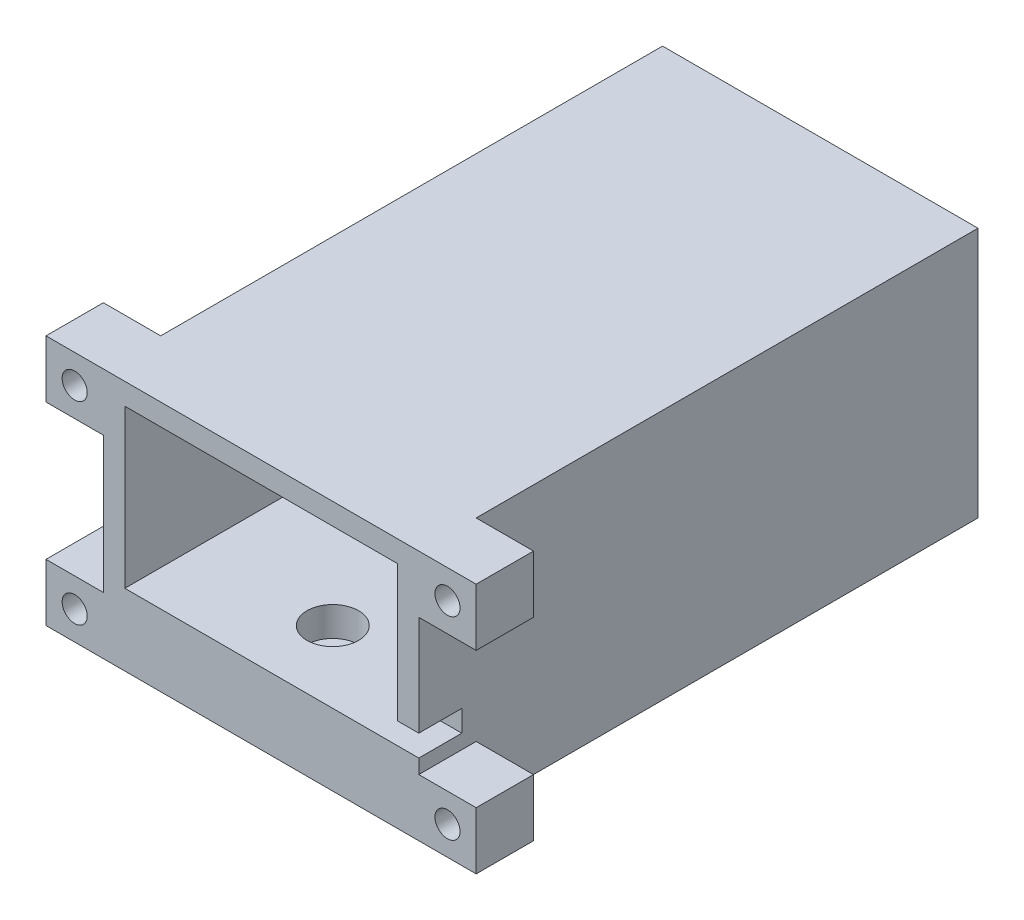
from build123d import *

# Parameters (mm, degrees)
SKETCH_1_W                 = 44
SKETCH_1_H                 = 78
EXTRUDE_1_DEPTH            = 35
SHELL_1_T                  = -3
SHELL_1_THICKNESS_2_FACE_W = 75
SHELL_1_THICKNESS_2_FACE_H = 38
SHELL_1_THICKNESS_2_DEPTH  = 7
SKETCH_3_R                 = 3.6
CUT_EXTRUDE_1_DEPTH        = 4.1
CUT_EXTRUDE_2_REACH        = 53.284
SKETCH_4_R                 = 2.25
SKETCH_5_W                 = 3
SKETCH_5_H                 = 3
CUT_EXTRUDE_3_DEPTH        = 6
SKETCH_6_W                 = 8
SKETCH_6_H                 = 8
SKETCH_6_R                 = 1.75
EXTRUDE_2_DEPTH            = 8
CUT_EXTRUDE_4_DEPTH        = 2.6
CUT_EXTRUDE_5_REACH        = 90.034
SKETCH_8_R                 = 5


with BuildPart() as part:
    # 草圖1 → 填料-伸長1 (new body)
    with BuildSketch(Plane(origin=(0, 0, 0), x_dir=(1, 0, 0), z_dir=(0, 1, 0))):
        Rectangle(SKETCH_1_W, SKETCH_1_H)
    extrude(amount=EXTRUDE_1_DEPTH)

    # 薄殼1
    shell_1_openings = [part.faces().sort_by_distance(p)[0] for p in [
        (0, 17.5, 39),
    ]]
    offset(amount=SHELL_1_T, openings=shell_1_openings, kind=Kind.INTERSECTION)

    # 薄殼1 thickness 2 face (on inner face of the shell) → 薄殼1 thickness 2 (add)
    with BuildSketch(Plane(origin=(0, 3, 1.5), x_dir=(0, 0, -1), z_dir=(0, -1, 0))):
        Rectangle(SHELL_1_THICKNESS_2_FACE_W, SHELL_1_THICKNESS_2_FACE_H)
    extrude(amount=-SHELL_1_THICKNESS_2_DEPTH)

    # 草圖3 → 除料-伸長1 (cut)
    with BuildSketch(Plane(origin=(0, 10, 0), x_dir=(1, 0, 0), z_dir=(0, 1, 0))):
        with Locations(Location((0, 25, 0), (0, 0, 270))):
            Circle(SKETCH_3_R)
        with Locations(Location((0, -29, 0), (0, 0, 270))):
            Circle(SKETCH_3_R)
    extrude(amount=-CUT_EXTRUDE_1_DEPTH, mode=Mode.SUBTRACT)

    # 草圖4 → 除料-伸長2 (cut, up to next)
    with BuildSketch(Plane(origin=(0, 10, 0), x_dir=(1, 0, 0), z_dir=(0, 1, 0)), mode=Mode.PRIVATE) as cut_extrude_2_sk1:
        with Locations(Location((0, 25, 0), (0, 0, 270))):
            Circle(SKETCH_4_R)
    cut_extrude_2_tool1 = extrude(cut_extrude_2_sk1.sketch, amount=-CUT_EXTRUDE_2_REACH, mode=Mode.PRIVATE) & part.part
    # 草圖4 → 除料-伸長2 (cut, up to next)
    with BuildSketch(Plane(origin=(0, 10, 0), x_dir=(1, 0, 0), z_dir=(0, 1, 0)), mode=Mode.PRIVATE) as cut_extrude_2_sk2:
        with Locations(Location((0, -29, 0), (0, 0, 270))):
            Circle(SKETCH_4_R)
    cut_extrude_2_tool2 = extrude(cut_extrude_2_sk2.sketch, amount=-CUT_EXTRUDE_2_REACH, mode=Mode.PRIVATE) & part.part
    add(cut_extrude_2_tool1.solids().sort_by_distance((0, 10, -25))[0], mode=Mode.SUBTRACT)
    add(cut_extrude_2_tool2.solids().sort_by_distance((0, 10, 29))[0], mode=Mode.SUBTRACT)

    # 草圖5 → 除料-伸長3 (cut)
    with BuildSketch(Plane.XY.offset(39)):
        with Locations((20.5, 11.5)):
            Rectangle(SKETCH_5_W, SKETCH_5_H)
    extrude(amount=-CUT_EXTRUDE_3_DEPTH, mode=Mode.SUBTRACT)

    # 草圖6 → 填料-伸長2 (add)
    with BuildSketch(Plane.XY.offset(39)):
        with Locations((-26, 31)):
            Rectangle(SKETCH_6_W, SKETCH_6_H)
        with Locations((-26, 31)):
            Circle(SKETCH_6_R, mode=Mode.SUBTRACT)
        with Locations((-26, 4)):
            Rectangle(SKETCH_6_W, SKETCH_6_H)
        with Locations((-26, 4)):
            Circle(SKETCH_6_R, mode=Mode.SUBTRACT)
        with Locations((26, 4)):
            Rectangle(SKETCH_6_W, SKETCH_6_H)
        with Locations(Location((26, 4, 0), (0, 0, 180))):
            Circle(SKETCH_6_R, mode=Mode.SUBTRACT)
        with Locations((26, 31)):
            Rectangle(SKETCH_6_W, SKETCH_6_H)
        with Locations(Location((26, 31, 0), (0, 0, 180))):
            Circle(SKETCH_6_R, mode=Mode.SUBTRACT)
    extrude(amount=-EXTRUDE_2_DEPTH)

    # 草圖7 → 除料-伸長4 (cut)
    with BuildSketch(Plane(origin=(0, 0, 31), x_dir=(-1, 0, 0), z_dir=(0, 0, -1))):
        Polygon((27.58771324, 6.75), (29.175426481, 4), (27.58771324, 1.25), (24.41228676, 1.25), (22.824573519, 4), (24.41228676, 6.75), align=None)
        Polygon((-22.824573519, 31), (-24.41228676, 33.75), (-27.58771324, 33.75), (-29.175426481, 31), (-27.58771324, 28.25), (-24.41228676, 28.25), align=None)
        Polygon((-29.175426481, 4), (-27.58771324, 1.25), (-24.41228676, 1.25), (-22.824573519, 4), (-24.41228676, 6.75), (-27.58771324, 6.75), align=None)
        Polygon((24.41228676, 28.25), (22.824573519, 31), (24.41228676, 33.75), (27.58771324, 33.75), (29.175426481, 31), (27.58771324, 28.25), align=None)
    extrude(amount=-CUT_EXTRUDE_4_DEPTH, mode=Mode.SUBTRACT)

    # 草圖8 → 除料-伸長5 (cut, up to next)
    with BuildSketch(Plane.XY.offset(-36), mode=Mode.PRIVATE) as cut_extrude_5_sk1:
        with Locations((0, 20)):
            Circle(SKETCH_8_R)
    cut_extrude_5_tool1 = extrude(cut_extrude_5_sk1.sketch, amount=-CUT_EXTRUDE_5_REACH, mode=Mode.PRIVATE) & part.part
    add(cut_extrude_5_tool1.solids().sort_by_distance((0, 20, -36))[0], mode=Mode.SUBTRACT)


solid = part.part
